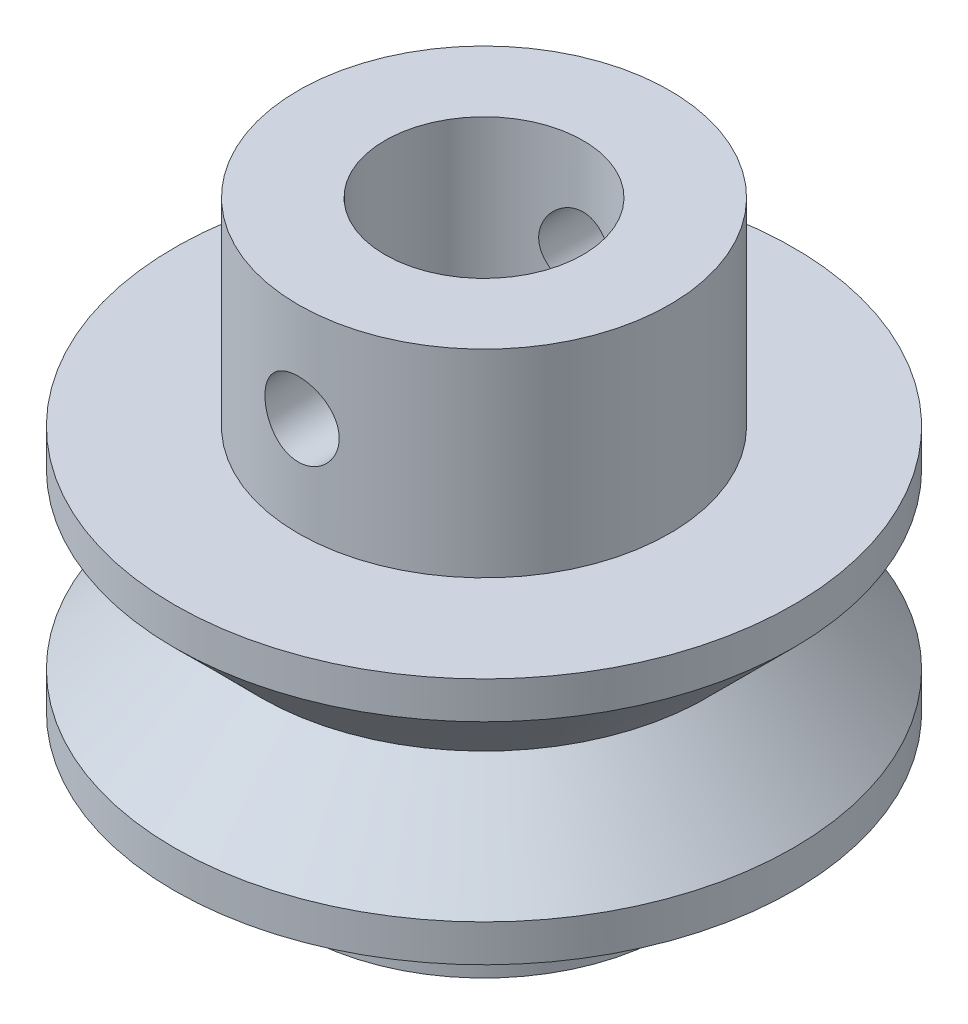
from build123d import *

# Parameters (mm, degrees)
BOSS_EXTRUDE1_DEPTH      = 13
BOSS_EXTRUDE1_DEPTH_BACK = 9
SKETCH1_R                = 7.5
SKETCH1_R_2              = 4
BOSS_EXTRUDE2_DEPTH      = 5
BOSS_EXTRUDE2_DEPTH_BACK = 5
SKETCH1_4_R              = 12.5
SKETCH1_4_R_2            = 7.5
CUT_EXTRUDE1_DEPTH       = 22.943108257
CUT_EXTRUDE1_DEPTH_BACK  = 22.943108257
SKETCH3_R                = 1.5


with BuildPart() as part:
    # Sketch1 → Boss-Extrude1 (new, two sides: drawn at the far end of the back side and taken through both)
    with BuildSketch(Plane(origin=(0, 0, 0), x_dir=(1, 0, 0), z_dir=(0, 1, 0)).offset(-BOSS_EXTRUDE1_DEPTH_BACK)):
        Circle(SKETCH1_R)
        Circle(SKETCH1_R_2, mode=Mode.SUBTRACT)
    extrude(amount=BOSS_EXTRUDE1_DEPTH + BOSS_EXTRUDE1_DEPTH_BACK)

    # Sketch1_4 → Boss-Extrude2 (add, two sides: drawn at the far end of the back side and taken through both)
    with BuildSketch(Plane(origin=(0, 0, 0), x_dir=(1, 0, 0), z_dir=(0, 1, 0)).offset(-BOSS_EXTRUDE2_DEPTH_BACK)):
        Circle(SKETCH1_4_R)
        Circle(SKETCH1_4_R_2, mode=Mode.SUBTRACT)
    extrude(amount=BOSS_EXTRUDE2_DEPTH + BOSS_EXTRUDE2_DEPTH_BACK)

    # Sketch2 → Cut-Revolve1 (revolve, cut)
    with BuildSketch(Plane(origin=(0, 0, 0), x_dir=(0, 0, -1), z_dir=(1, 0, 0))):
        Polygon((-9, 0), (-12.5, 3.5), (-12.5, -3.5), align=None)
    revolve(axis=Axis((0, 0, 0), (0, 1, 0)), mode=Mode.SUBTRACT)

    # Sketch3 → Cut-Extrude1 (cut, two sides: drawn at the far end of the back side and taken through both)
    with BuildSketch(Plane.XY.offset(-CUT_EXTRUDE1_DEPTH_BACK)):
        with Locations((0, 9)):
            Circle(SKETCH3_R)
    extrude(amount=CUT_EXTRUDE1_DEPTH + CUT_EXTRUDE1_DEPTH_BACK, mode=Mode.SUBTRACT)


solid = part.part
